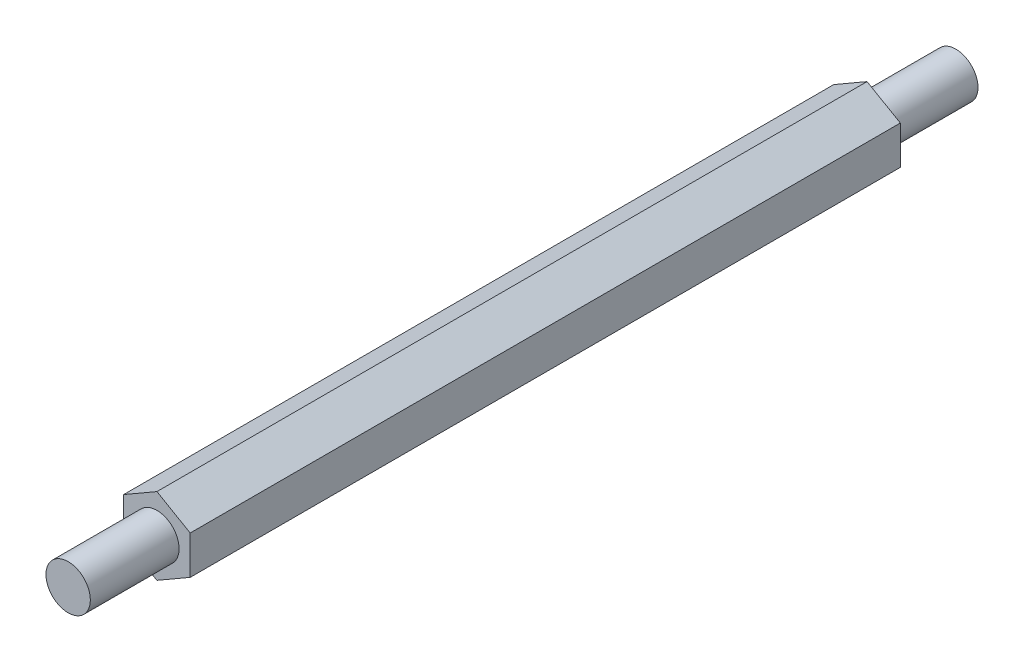
from build123d import *

# Parameters (mm, degrees)
BOSS_EXTRUDE1_DEPTH      = 101.6
SKETCH2_R                = 6.35
BOSS_EXTRUDE2_DEPTH      = 127
BOSS_EXTRUDE2_DEPTH_BACK = 127


with BuildPart() as part:
    # Sketch1 → Boss-Extrude1 (new body, symmetric)
    with BuildSketch(Plane.XY):
        Polygon((0, 10.998522628), (-9.525, 5.499261314), (-9.525, -5.499261314), (0, -10.998522628), (9.525, -5.499261314), (9.525, 5.499261314), align=None)
    extrude(amount=BOSS_EXTRUDE1_DEPTH, both=True)

    # Sketch2 → Boss-Extrude2 (add, two sides)
    with BuildSketch(Plane.XY) as boss_extrude2_sk:
        Circle(SKETCH2_R)
    extrude(amount=BOSS_EXTRUDE2_DEPTH)
    extrude(boss_extrude2_sk.sketch, amount=-BOSS_EXTRUDE2_DEPTH_BACK)


solid = part.part
